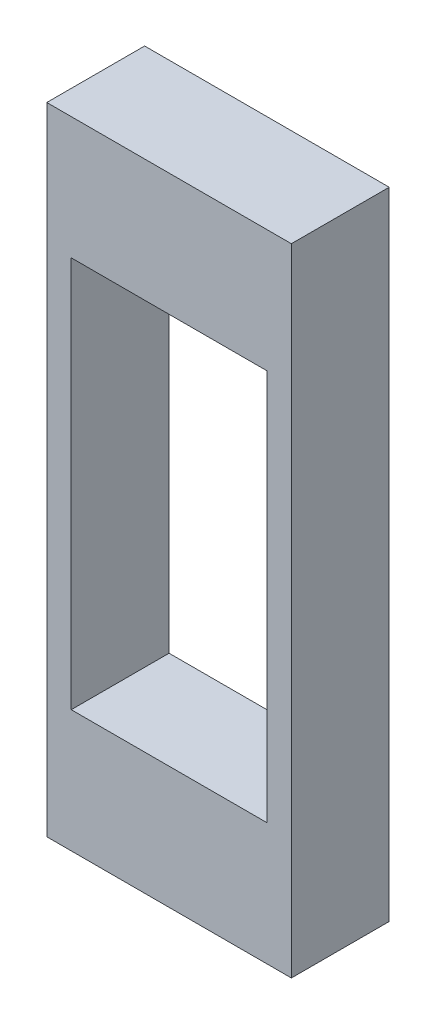
from build123d import *

# Parameters (mm, degrees)
SKETCH1_W           = 25.4
SKETCH1_H           = 66.04
SKETCH1_W_2         = 20.32
SKETCH1_H_2         = 40.64
BOSS_EXTRUDE1_DEPTH = 10.16


with BuildPart() as part:
    # Sketch1 → Boss-Extrude1 (new body)
    with BuildSketch(Plane.XY):
        Rectangle(SKETCH1_W, SKETCH1_H)
        Rectangle(SKETCH1_W_2, SKETCH1_H_2, mode=Mode.SUBTRACT)
    extrude(amount=BOSS_EXTRUDE1_DEPTH)


solid = part.part
